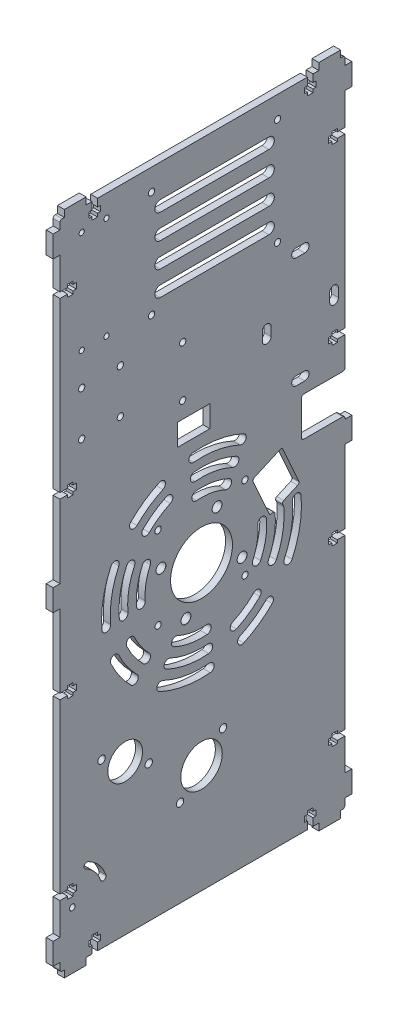
from build123d import *

# Parameters (mm, degrees)
SKETCH1_W                                    = 131.144223413
SKETCH1_H                                    = 300
SKETCH1_R                                    = 14.25
TRANSMISSION_DEPTH                           = 1.5875
MOTORCLEARANCEHOLES_D                        = 4.5
MOTORCLEARANCEHOLES_CSINK_D                  = 4.55
MOTORCLEARANCEHOLES_CSINK_ANGLE              = 100
MOTORWIRESCUTOUT_DEPTH                       = 2.5875
MOTORWIRESCUTOUT_DEPTH_BACK                  = 2.5875
MOTORDRIVERHOLES_D                           = 2.9
VENTS_DEPTH                                  = 2.5875
VENTPATTERN_COUNT                            = 4
SKETCH9_R                                    = 7.9875
SKETCH9_R_2                                  = 9.55
BEARINGHOLES_DEPTH                           = 2.5875
BEARINGHOLES_DEPTH_BACK                      = 2.5875
BEARINGCOVERHOLES_D                          = 3.4
SKETCH17_R                                   = 1.3
CUT_EXTRUDE1_DEPTH                           = 2.5875
CUT_EXTRUDE1_DEPTH_BACK                      = 2.5875
ELECTRONICS_DEPTH                            = 2.5875
ELECTRONICS_DEPTH_BACK                       = 2.5875
M2_5ELECTRONICSHOLES_D                       = 2.9
SKETCH21_W                                   = 15
SKETCH21_H                                   = 10
SKETCH21_W_2                                 = 20
SKETCH21_H_2                                 = 18
WIRECUTOUT_DEPTH                             = 2.5875
WIRECUTOUT_DEPTH_BACK                        = 2.5875
VENT2_DEPTH                                  = 2.5875
VENT2PATTERN_COUNT                           = 3
VENT2PATTERN_ANGLE                           = 180
M2_CLEARANCE_HOLE1_D                         = 2.4
SKETCH24_W                                   = 3.175
SKETCH24_H                                   = 10
SKETCH24_W_2                                 = 10
SKETCH24_H_2                                 = 3.175
BOSS_EXTRUDE1_DEPTH                          = 3.175
CUT_EXTRUDE2_START                           = -4.175
SKETCH25_W                                   = 7.5
SKETCH25_H                                   = 2.6
SKETCH25_W_2                                 = 2.5
SKETCH25_H_2                                 = 5.2
CUT_EXTRUDE2_DEPTH                           = 5.175
LPATTERN1_COUNT                              = 4
LPATTERN1_PITCH                              = 80
MIRROR1_START                                = -4.175
MIRROR1_COPY_1_SKETCH_W                      = 7.5
MIRROR1_COPY_1_SKETCH_H                      = 2.6
MIRROR1_COPY_1_SKETCH_W_2                    = 2.5
MIRROR1_COPY_1_SKETCH_H_2                    = 5.2
MIRROR1_COPY_1_DEPTH                         = 5.175
MIRROR1_COPY_2_SKETCH_W                      = 7.5
MIRROR1_COPY_2_SKETCH_H                      = 2.6
MIRROR1_COPY_2_SKETCH_W_2                    = 2.5
MIRROR1_COPY_2_SKETCH_H_2                    = 5.2
MIRROR1_COPY_2_DEPTH                         = 5.175
MIRROR1_COPY_3_SKETCH_W                      = 7.5
MIRROR1_COPY_3_SKETCH_H                      = 2.6
MIRROR1_COPY_3_SKETCH_W_2                    = 2.5
MIRROR1_COPY_3_SKETCH_H_2                    = 5.2
MIRROR1_COPY_3_DEPTH                         = 5.175
CUT_EXTRUDE3_DEPTH                           = 1
CUT_EXTRUDE3_DEPTH_BACK                      = 4.175
FILLET1_R                                    = 1
CUT_EXTRUDE5_START                           = -4.1750001
SKETCH27_W                                   = 2.6
SKETCH27_H                                   = 7.5
SKETCH27_W_2                                 = 5.2
SKETCH27_H_2                                 = 2.5
CUT_EXTRUDE5_DEPTH                           = 5.1750002
MIRROR2_START                                = -4.1750001
MIRROR2_AT_THE_SECOND_PLANE_COPY_1_SKETC_W   = 2.6
MIRROR2_AT_THE_SECOND_PLANE_COPY_1_SKETC_H   = 7.5
MIRROR2_AT_THE_SECOND_PLANE_COPY_1_SKETC_W_2 = 5.2
MIRROR2_AT_THE_SECOND_PLANE_COPY_1_SKETC_H_2 = 2.5
MIRROR2_AT_THE_SECOND_PLANE_COPY_1_DEPTH     = 5.1750002
FILLET2_R                                    = 1


with BuildPart() as part:
    # Sketch1 → Transmission (new body, symmetric)
    with BuildSketch(Plane(origin=(0, 0, 0), x_dir=(0, 0, -1), z_dir=(1, 0, 0))):
        with Locations((0.427888293, 19.206230873)):
            Rectangle(SKETCH1_W, SKETCH1_H)
        Circle(SKETCH1_R, mode=Mode.SUBTRACT)
    extrude(amount=TRANSMISSION_DEPTH, both=True)

    # MotorClearanceHoles (through all)
    with Locations(Plane(origin=(1.5875, 0, 0), x_dir=(0, 0, -1), z_dir=(1, 0, 0))):
        with Locations((7.167358991, 18.67160853), (-18.67160853, 7.167358991), (-7.167358991, -18.67160853), (18.67160853, -7.167358991)):
            CounterSinkHole(MOTORCLEARANCEHOLES_D / 2, MOTORCLEARANCEHOLES_CSINK_D / 2, counter_sink_angle=MOTORCLEARANCEHOLES_CSINK_ANGLE)

    # Sketch16 → MotorWiresCutout (cut, two sides)
    with BuildSketch(Plane(origin=(0, 0, 0), x_dir=(0, 0, -1), z_dir=(1, 0, 0))) as motorwirescutout_sk:
        Polygon((37.042179163, 27.438603515), (45.176912025, 9.167694362), (31.47373016, 3.066644716), (23.338997299, 21.337553869), align=None)
    extrude(amount=MOTORWIRESCUTOUT_DEPTH, mode=Mode.SUBTRACT)
    extrude(motorwirescutout_sk.sketch, amount=-MOTORWIRESCUTOUT_DEPTH_BACK, mode=Mode.SUBTRACT)

    # MotorDriverHoles (through all)
    with Locations(Plane(origin=(1.5875, 0, 0), x_dir=(0, 0, -1), z_dir=(1, 0, 0))):
        with Locations((20, 23), (20, -15), (-20, -15), (-20, 23)):
            Hole(MOTORDRIVERHOLES_D / 2)

    # Sketch4 → Vents (cut, symmetric)
    with BuildSketch(Plane(origin=(0, 0, 0), x_dir=(0, 0, -1), z_dir=(1, 0, 0))):
        with BuildLine():
            ThreePointArc((16.059493946, 34.439695907), (6.598630751, 37.422694614), (-3.311918224, 37.855398527))
            ThreePointArc((-3.311918224, 37.855398527), (-5.129996135, 35.688697646), (-2.963295253, 33.870619735))
            ThreePointArc((-2.963295253, 33.870619735), (5.904038041, 33.483463602), (14.369020899, 30.814464759))
            ThreePointArc((14.369020899, 30.814464759), (17.026872997, 31.78184381), (16.059493946, 34.439695907))
        make_face()
        with BuildLine():
            ThreePointArc((12.678547852, 27.189233611), (5.20944533, 29.54423259), (-2.614672282, 29.885840943))
            ThreePointArc((-2.614672282, 29.885840943), (-4.432750193, 27.719140061), (-2.266049311, 25.90106215))
            ThreePointArc((-2.266049311, 25.90106215), (4.514852619, 25.605001578), (10.988074805, 23.564002463))
            ThreePointArc((10.988074805, 23.564002463), (13.645926903, 24.531381514), (12.678547852, 27.189233611))
        make_face()
        with BuildLine():
            ThreePointArc((19.44044004, 41.690158204), (7.987816173, 45.301156639), (-4.009164166, 45.824956112))
            ThreePointArc((-4.009164166, 45.824956112), (-5.827242077, 43.658255231), (-3.660541195, 41.84017732))
            ThreePointArc((-3.660541195, 41.84017732), (7.293223462, 41.361925627), (17.749966993, 38.064927056))
            ThreePointArc((17.749966993, 38.064927056), (20.407819091, 39.032306106), (19.44044004, 41.690158204))
        make_face()
    vents = extrude(amount=VENTS_DEPTH, both=True, mode=Mode.SUBTRACT)

    # VentPattern: Vents ×4 about axis
    ventpattern_axis = Axis((0, 0, 0), (1, 0, 0))
    for i in range(1, VENTPATTERN_COUNT):
        add(vents.rotate(ventpattern_axis, i * 360 / VENTPATTERN_COUNT), mode=Mode.SUBTRACT)

    # Sketch9 → BearingHoles (cut, two sides)
    with BuildSketch(Plane(origin=(0, 0, 0), x_dir=(0, 0, -1), z_dir=(1, 0, 0))) as bearingholes_sk:
        with Locations((-35.144223413, -61.691843551)):
            Circle(SKETCH9_R)
        with Locations((0, -80.793769127)):
            Circle(SKETCH9_R_2)
    extrude(amount=BEARINGHOLES_DEPTH, mode=Mode.SUBTRACT)
    extrude(bearingholes_sk.sketch, amount=-BEARINGHOLES_DEPTH_BACK, mode=Mode.SUBTRACT)

    # BearingCoverHoles (through all)
    with Locations(Plane(origin=(1.5875, 0, 0), x_dir=(0, 0, -1), z_dir=(1, 0, 0))):
        with Locations((-46.005463475, -55.504480274), (-24.282983351, -67.879206828), (9.899494937, -70.89427419), (-9.899494937, -90.693264063)):
            Hole(BEARINGCOVERHOLES_D / 2)

    # Sketch17 → Cut-Extrude1 (cut, two sides)
    with BuildSketch(Plane(origin=(0, 0, 0), x_dir=(0, 0, -1), z_dir=(1, 0, 0))) as cut_extrude1_sk:
        with Locations((-59.46656593, -107.644793994)):
            Circle(SKETCH17_R)
        with BuildLine():
            ThreePointArc((-44.007743917, -102.476155686), (-47.162428924, -96.953759782), (-52.190307253, -93.058976922))
            ThreePointArc((-52.190307253, -93.058976922), (-53.933908386, -93.641947837), (-53.350937471, -95.385548971))
            ThreePointArc((-53.350937471, -95.385548971), (-49.125052005, -98.659078123), (-46.473568287, -103.30060106))
            ThreePointArc((-46.473568287, -103.30060106), (-44.828433415, -104.121290558), (-44.007743917, -102.476155686))
        make_face()
    extrude(amount=CUT_EXTRUDE1_DEPTH, mode=Mode.SUBTRACT)
    extrude(cut_extrude1_sk.sketch, amount=-CUT_EXTRUDE1_DEPTH_BACK, mode=Mode.SUBTRACT)

    # ElectronicsSketch → Electronics (cut, two sides)
    with BuildSketch(Plane(origin=(0, 0, 0), x_dir=(0, 0, -1), z_dir=(1, 0, 0))) as electronics_sk:
        with BuildLine():
            Line((32, 78.206230873), (32, 74.206230873))
            ThreePointArc((32, 74.206230873), (30, 72.206230873), (28, 74.206230873))
            Line((28, 74.206230873), (28, 78.206230873))
            ThreePointArc((28, 78.206230873), (30, 80.206230873), (32, 78.206230873))
        make_face()
        with BuildLine():
            Line((63, 78.206230873), (63, 74.206230873))
            ThreePointArc((63, 74.206230873), (61, 72.206230873), (59, 74.206230873))
            Line((59, 74.206230873), (59, 78.206230873))
            ThreePointArc((59, 78.206230873), (61, 80.206230873), (63, 78.206230873))
        make_face()
        with BuildLine():
            Line((43.5, 103.706230873), (47.5, 103.706230873))
            ThreePointArc((47.5, 103.706230873), (49.5, 101.706230873), (47.5, 99.706230873))
            Line((47.5, 99.706230873), (43.5, 99.706230873))
            ThreePointArc((43.5, 99.706230873), (41.5, 101.706230873), (43.5, 103.706230873))
        make_face()
        with BuildLine():
            Line((43.5, 52.706230873), (47.5, 52.706230873))
            ThreePointArc((47.5, 52.706230873), (49.5, 50.706230873), (47.5, 48.706230873))
            Line((47.5, 48.706230873), (43.5, 48.706230873))
            ThreePointArc((43.5, 48.706230873), (41.5, 50.706230873), (43.5, 52.706230873))
        make_face()
    extrude(amount=ELECTRONICS_DEPTH, mode=Mode.SUBTRACT)
    extrude(electronics_sk.sketch, amount=-ELECTRONICS_DEPTH_BACK, mode=Mode.SUBTRACT)

    # M2.5ElectronicsHoles (through all)
    with Locations(Plane(origin=(1.5875, 0, 0), x_dir=(0, 0, -1), z_dir=(1, 0, 0))):
        with Locations((-8.664223413, 68.981230873), (-8.664223413, 92.231230873), (-55.144223413, 76.886230873), (-37.364223413, 76.886230873), (-37.364223413, 97.206230873), (-55.144223413, 97.206230873), (35, 110.206230873), (-23, 110.206230873), (-23, 159.206230873), (35, 159.206230873)):
            Hole(M2_5ELECTRONICSHOLES_D / 2)

    # Sketch21 → WireCutout (cut, two sides)
    with BuildSketch(Plane(origin=(0, 0, 0), x_dir=(0, 0, -1), z_dir=(1, 0, 0))) as wirecutout_sk:
        with Locations((-3.664223413, 56.506230873)):
            Rectangle(SKETCH21_W, SKETCH21_H)
        with Locations((56, 34.706230873)):
            Rectangle(SKETCH21_W_2, SKETCH21_H_2)
    extrude(amount=WIRECUTOUT_DEPTH, mode=Mode.SUBTRACT)
    extrude(wirecutout_sk.sketch, amount=-WIRECUTOUT_DEPTH_BACK, mode=Mode.SUBTRACT)

    # Sketch4_3 → Vent2 (cut, symmetric)
    with BuildSketch(Plane(origin=(0, 0, 0), x_dir=(0, 0, -1), z_dir=(1, 0, 0))):
        with BuildLine():
            ThreePointArc((-19.44044004, 41.690158204), (-26.384516072, 37.680994037), (-32.526911935, 32.526911935))
            ThreePointArc((-32.526911935, 32.526911935), (-32.526911935, 29.69848481), (-29.69848481, 29.69848481))
            ThreePointArc((-29.69848481, 29.69848481), (-24.090210327, 34.40438586), (-17.749966993, 38.064927056))
            ThreePointArc((-17.749966993, 38.064927056), (-16.782587943, 40.722779153), (-19.44044004, 41.690158204))
        make_face()
        with BuildLine():
            ThreePointArc((-16.059493946, 34.439695907), (-21.795904581, 31.127777683), (-26.870057685, 26.870057685))
            ThreePointArc((-26.870057685, 26.870057685), (-26.870057685, 24.04163056), (-24.04163056, 24.04163056))
            ThreePointArc((-24.04163056, 24.04163056), (-19.501598836, 27.851169506), (-14.369020899, 30.814464759))
            ThreePointArc((-14.369020899, 30.814464759), (-13.401641849, 33.472316857), (-16.059493946, 34.439695907))
        make_face()
    vent2 = extrude(amount=VENT2_DEPTH, both=True, mode=Mode.SUBTRACT)

    # Vent2Pattern: Vent2 ×3 about axis
    vent2pattern_axis = Axis((0, 0, 0), (1, 0, 0))
    for i in range(1, VENT2PATTERN_COUNT):
        add(vent2.rotate(vent2pattern_axis, i * VENT2PATTERN_ANGLE / (VENT2PATTERN_COUNT - 1)), mode=Mode.SUBTRACT)

    # M2 Clearance Hole1 (through all)
    with Locations(Plane(origin=(1.5875, 0, 0), x_dir=(0, 0, -1), z_dir=(1, 0, 0))):
        with Locations((-55.144223413, 159.206230873), (-43.744223413, 159.206230873), (-43.744223413, 112.206230873), (-55.144223413, 112.206230873)):
            Hole(M2_CLEARANCE_HOLE1_D / 2)

    # Sketch24 → Boss-Extrude1 (add)
    with BuildSketch(Plane(origin=(1.5875, 0, 0), x_dir=(0, 0, -1), z_dir=(1, 0, 0))):
        with Locations((-66.731723413, 160.206230873)):
            Rectangle(SKETCH24_W, SKETCH24_H)
        with Locations((-66.731723413, 19.206230873)):
            Rectangle(SKETCH24_W, SKETCH24_H)
        with Locations((-66.731723413, -121.793769127)):
            Rectangle(SKETCH24_W, SKETCH24_H)
        with Locations((-58.144223413, 170.793730873)):
            Rectangle(SKETCH24_W_2, SKETCH24_H_2)
        with Locations((59, 170.793730873)):
            Rectangle(SKETCH24_W_2, SKETCH24_H_2)
        with Locations((-58.144223413, -132.381269127)):
            Rectangle(SKETCH24_W_2, SKETCH24_H_2)
        with Locations((59, -132.381269127)):
            Rectangle(SKETCH24_W_2, SKETCH24_H_2)
    boss_extrude1 = extrude(amount=-BOSS_EXTRUDE1_DEPTH)

    # Sketch25 → Cut-Extrude2 (cut)
    with BuildSketch(Plane(origin=(1.5875, 0, 0), x_dir=(0, 0, -1), z_dir=(1, 0, 0)).offset(CUT_EXTRUDE2_START)):
        with Locations((-61.394223413, 139.206230873)):
            Rectangle(SKETCH25_W, SKETCH25_H)
        with Locations((-60.394223413, 139.206230873)):
            Rectangle(SKETCH25_W_2, SKETCH25_H_2)
    cut_extrude2 = extrude(amount=CUT_EXTRUDE2_DEPTH, mode=Mode.SUBTRACT)

    # LPattern1: Cut-Extrude2 ×4
    with Locations(*[(0, -i * LPATTERN1_PITCH, 0) for i in range(1, LPATTERN1_COUNT)]):
        add(cut_extrude2, mode=Mode.SUBTRACT)

    # Mirror1: Cut-Extrude2, Boss-Extrude1 across plane
    add(cut_extrude2.mirror(Plane.XY.offset(-0.427888294)), mode=Mode.SUBTRACT)
    add(boss_extrude1.mirror(Plane.XY.offset(-0.427888294)))

    # Mirror1 copy 1 sketch → Mirror1 copy 1 (cut)
    with BuildSketch(Plane(origin=(1.5875, -80, -0.855776587), x_dir=(0, 0, 1), z_dir=(1, 0, 0)).offset(MIRROR1_START)):
        with Locations((-61.394223413, -139.206230873)):
            Rectangle(MIRROR1_COPY_1_SKETCH_W, MIRROR1_COPY_1_SKETCH_H)
        with Locations((-60.394223413, -139.206230873)):
            Rectangle(MIRROR1_COPY_1_SKETCH_W_2, MIRROR1_COPY_1_SKETCH_H_2)
    extrude(amount=MIRROR1_COPY_1_DEPTH, mode=Mode.SUBTRACT)

    # Mirror1 copy 2 sketch → Mirror1 copy 2 (cut)
    with BuildSketch(Plane(origin=(1.5875, -160, -0.855776587), x_dir=(0, 0, 1), z_dir=(1, 0, 0)).offset(MIRROR1_START)):
        with Locations((-61.394223413, -139.206230873)):
            Rectangle(MIRROR1_COPY_2_SKETCH_W, MIRROR1_COPY_2_SKETCH_H)
        with Locations((-60.394223413, -139.206230873)):
            Rectangle(MIRROR1_COPY_2_SKETCH_W_2, MIRROR1_COPY_2_SKETCH_H_2)
    extrude(amount=MIRROR1_COPY_2_DEPTH, mode=Mode.SUBTRACT)

    # Mirror1 copy 3 sketch → Mirror1 copy 3 (cut)
    with BuildSketch(Plane(origin=(1.5875, -240, -0.855776587), x_dir=(0, 0, 1), z_dir=(1, 0, 0)).offset(MIRROR1_START)):
        with Locations((-61.394223413, -139.206230873)):
            Rectangle(MIRROR1_COPY_3_SKETCH_W, MIRROR1_COPY_3_SKETCH_H)
        with Locations((-60.394223413, -139.206230873)):
            Rectangle(MIRROR1_COPY_3_SKETCH_W_2, MIRROR1_COPY_3_SKETCH_H_2)
    extrude(amount=MIRROR1_COPY_3_DEPTH, mode=Mode.SUBTRACT)

    # Sketch26 → Cut-Extrude3 (cut, two sides)
    with BuildSketch(Plane.ZY.offset(1.5875)) as cut_extrude3_sk:
        with BuildLine():
            Line((-31, 154.206230873), (19, 154.206230873))
            ThreePointArc((19, 154.206230873), (21.5, 151.706230873), (19, 149.206230873))
            Line((19, 149.206230873), (-31, 149.206230873))
            ThreePointArc((-31, 149.206230873), (-33.5, 151.706230873), (-31, 154.206230873))
        make_face()
        with BuildLine():
            Line((-31, 142.87289754), (19, 142.87289754))
            ThreePointArc((19, 142.87289754), (21.5, 140.37289754), (19, 137.87289754))
            Line((19, 137.87289754), (-31, 137.87289754))
            ThreePointArc((-31, 137.87289754), (-33.5, 140.37289754), (-31, 142.87289754))
        make_face()
        with BuildLine():
            Line((-31, 131.539564207), (19, 131.539564207))
            ThreePointArc((19, 131.539564207), (21.5, 129.039564207), (19, 126.539564207))
            Line((19, 126.539564207), (-31, 126.539564207))
            ThreePointArc((-31, 126.539564207), (-33.5, 129.039564207), (-31, 131.539564207))
        make_face()
        with BuildLine():
            Line((-31, 120.206230873), (19, 120.206230873))
            ThreePointArc((19, 120.206230873), (21.5, 117.706230873), (19, 115.206230873))
            Line((19, 115.206230873), (-31, 115.206230873))
            ThreePointArc((-31, 115.206230873), (-33.5, 117.706230873), (-31, 120.206230873))
        make_face()
    extrude(amount=CUT_EXTRUDE3_DEPTH, mode=Mode.SUBTRACT)
    extrude(cut_extrude3_sk.sketch, amount=-CUT_EXTRUDE3_DEPTH_BACK, mode=Mode.SUBTRACT)

    # Fillet1
    fillet1_edges = [part.edges().sort_by_distance(p)[0] for p in [
        (0, 5.124118776, -36.094892561),
        (0, 4.294519772, -34.23158269),
        (0, 2.963295253, -33.870619735),
        (0, 25.706230873, -46),
        (0, 43.706230873, -46),
        (0, 27.438603515, -37.042179163),
        (0, 9.167694362, -45.176912025),
        (0, 3.066644716, -31.47373016),
        (0, 21.337553869, -23.338997299),
    ]]
    fillet(fillet1_edges, radius=FILLET1_R)

    # Sketch27 → Cut-Extrude5 (cut)
    with BuildSketch(Plane(origin=(1.5875, 0, 0), x_dir=(0, 0, -1), z_dir=(1, 0, 0)).offset(CUT_EXTRUDE5_START)):
        with Locations((-49.144223413, 165.456230873)):
            Rectangle(SKETCH27_W, SKETCH27_H)
        with Locations((-49.144223413, 164.456230873)):
            Rectangle(SKETCH27_W_2, SKETCH27_H_2)
    cut_extrude5 = extrude(amount=CUT_EXTRUDE5_DEPTH, mode=Mode.SUBTRACT)

    # Mirror2: Cut-Extrude5 across plane
    add(cut_extrude5.mirror(Plane.ZX.offset(19.206230873)), mode=Mode.SUBTRACT)

    # Mirror2 at the second plane: Cut-Extrude5 across plane
    add(cut_extrude5.mirror(Plane.XY.offset(-0.427888294)), mode=Mode.SUBTRACT)

    # Mirror2 at the second plane copy 1 sketc → Mirror2 at the second plane copy 1 (cut)
    with BuildSketch(Plane(origin=(1.5875, 38.412461747, -0.855776587), x_dir=(0, 0, 1), z_dir=(1, 0, 0)).offset(MIRROR2_START)):
        with Locations((-49.144223413, 165.456230873)):
            Rectangle(MIRROR2_AT_THE_SECOND_PLANE_COPY_1_SKETC_W, MIRROR2_AT_THE_SECOND_PLANE_COPY_1_SKETC_H)
        with Locations((-49.144223413, 164.456230873)):
            Rectangle(MIRROR2_AT_THE_SECOND_PLANE_COPY_1_SKETC_W_2, MIRROR2_AT_THE_SECOND_PLANE_COPY_1_SKETC_H_2)
    extrude(amount=MIRROR2_AT_THE_SECOND_PLANE_COPY_1_DEPTH, mode=Mode.SUBTRACT)

    # Fillet2
    fillet2_edges = [part.edges().sort_by_distance(p)[0] for p in [
        (0, 43.706230873, -66),
        (0, 25.706230873, -66),
        (0, 169.206230873, 65.144223413),
        (0, 169.206230873, -66),
        (0, -130.793769127, -66),
        (0, -130.793769127, 65.144223413),
    ]]
    fillet(fillet2_edges, radius=FILLET2_R)


solid = part.part
